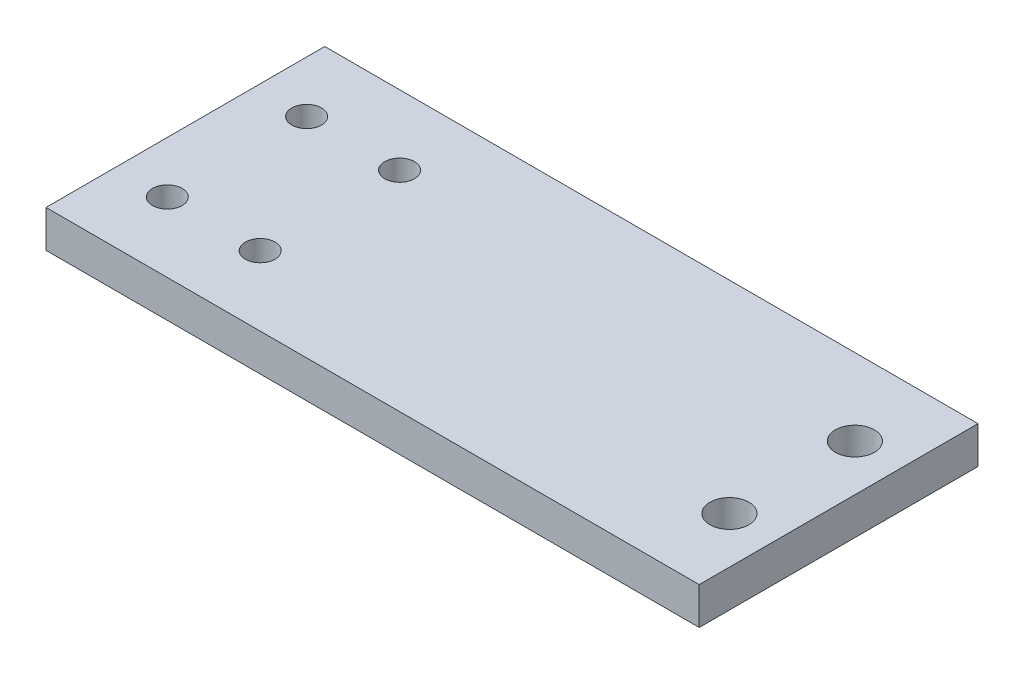
from build123d import *

# Parameters (mm, degrees)
SKETCH_1_W      = 70.3
SKETCH_1_H      = 30
SKETCH_1_R      = 1.6
SKETCH_1_R_2    = 2.1
EXTRUDE_1_DEPTH = 4


with BuildPart() as part:
    # 草图1 → 凸台-拉伸1 (new body)
    with BuildSketch(Plane(origin=(0, 0, 0), x_dir=(1, 0, 0), z_dir=(0, 1, 0))):
        with Locations((11.401803076, 7.998017492)):
            Rectangle(SKETCH_1_W, SKETCH_1_H)
        with Locations((-18.195488722, 15.498017492)):
            Circle(SKETCH_1_R, mode=Mode.SUBTRACT)
        with Locations((-18.195488722, 0.498017492)):
            Circle(SKETCH_1_R, mode=Mode.SUBTRACT)
        with Locations((-8.195488722, 15.498017492)):
            Circle(SKETCH_1_R, mode=Mode.SUBTRACT)
        with Locations((-8.195488722, 0.498017492)):
            Circle(SKETCH_1_R, mode=Mode.SUBTRACT)
        with Locations((41.551803076, 14.748017492)):
            Circle(SKETCH_1_R_2, mode=Mode.SUBTRACT)
        with Locations((41.551803076, 1.248017492)):
            Circle(SKETCH_1_R_2, mode=Mode.SUBTRACT)
    extrude(amount=EXTRUDE_1_DEPTH)


solid = part.part
